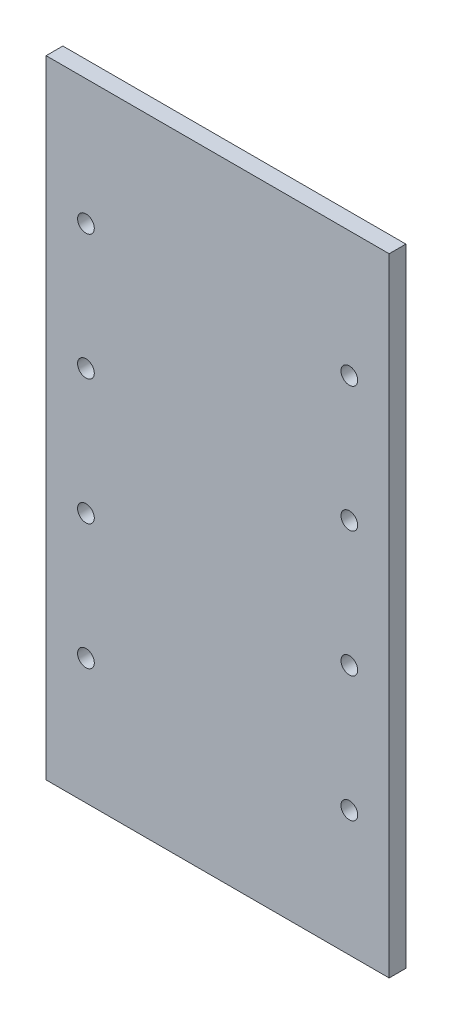
from build123d import *

# Parameters (mm, degrees)
SKETCH1_W           = 82.042
SKETCH1_H           = 150
BOSS_EXTRUDE1_DEPTH = 4
SKETCH2_R           = 2
CUT_EXTRUDE1_DEPTH  = 5


with BuildPart() as part:
    # Sketch1 → Boss-Extrude1 (new body)
    with BuildSketch(Plane.XY):
        with Locations((-21.971, 75)):
            Rectangle(SKETCH1_W, SKETCH1_H)
    extrude(amount=BOSS_EXTRUDE1_DEPTH)

    # Sketch2 → Cut-Extrude1 (cut, through all)
    with BuildSketch(Plane.XY.offset(4)):
        with Locations((-53.467, 30)):
            Circle(SKETCH2_R)
        with Locations((9.525, 30)):
            Circle(SKETCH2_R)
        with Locations((9.525, 60)):
            Circle(SKETCH2_R)
        with Locations((9.525, 90)):
            Circle(SKETCH2_R)
        with Locations((9.525, 120)):
            Circle(SKETCH2_R)
        with Locations((-53.467, 60)):
            Circle(SKETCH2_R)
        with Locations((-53.467, 90)):
            Circle(SKETCH2_R)
        with Locations((-53.467, 120)):
            Circle(SKETCH2_R)
    extrude(amount=-CUT_EXTRUDE1_DEPTH, mode=Mode.SUBTRACT)


solid = part.part
